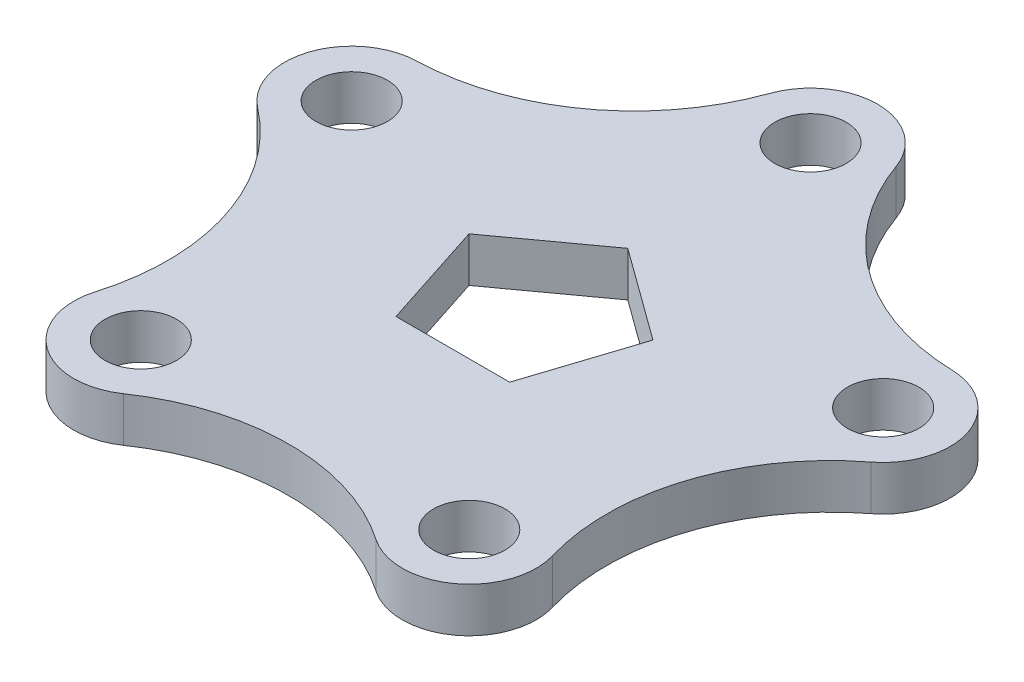
from build123d import *

# Parameters (mm, degrees)
SKETCH1_R           = 8
BOSS_EXTRUDE3_DEPTH = 10


with BuildPart() as part:
    # Sketch1 → Boss-Extrude3 (new body)
    with BuildSketch(Plane(origin=(0, 0, 0), x_dir=(1, 0, 0), z_dir=(0, 1, 0))):
        with BuildLine():
            ThreePointArc((14.132148934, 67.528157367), (31.850049433, 43.837832205), (59.85601991, 34.307820558))
            ThreePointArc((59.85601991, 34.307820558), (73.706880013, 23.948817064), (68.590168285, 7.426875892))
            ThreePointArc((68.590168285, 7.426875892), (51.534462525, -16.744561909), (51.125203669, -46.324758182))
            ThreePointArc((51.125203669, -46.324758182), (45.553357053, -62.698817064), (28.25890636, -62.938095635))
            ThreePointArc((28.25890636, -62.938095635), (0, -54.186540592), (-28.25890636, -62.938095635))
            ThreePointArc((-28.25890636, -62.938095635), (-45.553357053, -62.698817064), (-51.125203669, -46.324758182))
            ThreePointArc((-51.125203669, -46.324758182), (-51.534462525, -16.744561909), (-68.590168285, 7.426875892))
            ThreePointArc((-68.590168285, 7.426875892), (-73.706880013, 23.948817064), (-59.85601991, 34.307820558))
            ThreePointArc((-59.85601991, 34.307820558), (-31.850049433, 43.837832205), (-14.132148934, 67.528157367))
            ThreePointArc((-14.132148934, 67.528157367), (0, 77.5), (14.132148934, 67.528157367))
        make_face()
        with Locations((36.736578268, -50.563562148)):
            Circle(SKETCH1_R, mode=Mode.SUBTRACT)
        with Locations((-36.736578268, -50.563562148)):
            Circle(SKETCH1_R, mode=Mode.SUBTRACT)
        with Locations((59.441032268, 19.313562148)):
            Circle(SKETCH1_R, mode=Mode.SUBTRACT)
        with Locations((-59.441032268, 19.313562148)):
            Circle(SKETCH1_R, mode=Mode.SUBTRACT)
        with Locations((0, 62.5)):
            Circle(SKETCH1_R, mode=Mode.SUBTRACT)
        Polygon((20.57248383, 6.684405197), (0, 21.631189606), (-20.57248383, 6.684405197), (-12.71449424, -17.5), (12.71449424, -17.5), align=None, mode=Mode.SUBTRACT)
    extrude(amount=BOSS_EXTRUDE3_DEPTH)


solid = part.part
